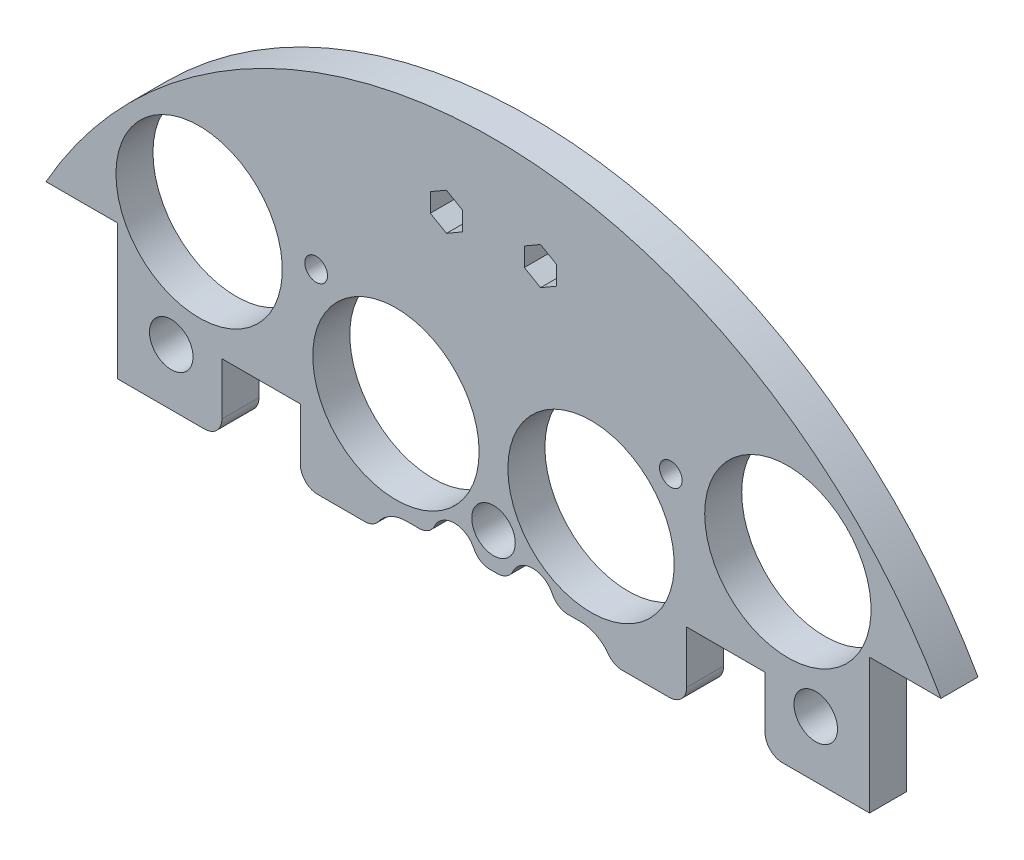
from build123d import *

# Parameters (mm, degrees)
SKETCH1_R                 = 1.651
BOSS_EXTRUDE2_DEPTH       = 5.3975
SKETCH2_R                 = 1.143
CUT_EXTRUDE1_DEPTH        = 6.3975
SKETCH3_R                 = 12.1285
CUT_EXTRUDE2_DEPTH        = 6.3975
SKETCH4_W                 = 28.562713242
SKETCH4_H                 = 11.677503754
BOSS_EXTRUDE3_DEPTH       = 5.3975
SKETCH5_W                 = 230.699333954
SKETCH5_H                 = 107.587024537
CUT_EXTRUDE3_DEPTH        = 6.3975
CUT_EXTRUDE4_DEPTH        = 6.3975
SKETCH156_W               = 11.43
SKETCH156_H               = 10.16
CUT_EXTRUDE152_DEPTH      = 6.3975
SKETCH164_R               = 1.651
CUT_EXTRUDE160_DEPTH      = 21.59
SKETCH218_R               = 3.175
CUT_EXTRUDE214_DEPTH      = 103.378
CUT_EXTRUDE214_DEPTH_BACK = 48.768
CUT_EXTRUDE155_DEPTH      = 34.544
FILLET1_R                 = 2.54


with BuildPart() as part:
    # Sketch1 → Boss-Extrude2 (new body)
    with BuildSketch(Plane.XY):
        with BuildLine():
            Line((-65.2537815, 36.83), (-54.8397815, 36.83))
            Line((-54.8397815, 36.83), (-54.8397815, -36.83))
            Line((-54.8397815, -36.83), (-65.2537815, -36.83))
            ThreePointArc((-65.2537815, -36.83), (0, -74.93), (65.2537815, -36.83))
            Line((65.2537815, -36.83), (54.8397815, -36.83))
            Line((54.8397815, -36.83), (54.8397815, 36.83))
            Line((54.8397815, 36.83), (65.2537815, 36.83))
            ThreePointArc((65.2537815, 36.83), (0, 74.93), (-65.2537815, 36.83))
        make_face()
        with Locations((-45.466, 11.049)):
            Circle(SKETCH1_R, mode=Mode.SUBTRACT)
        with Locations((-20.067270032, 10.795)):
            Circle(SKETCH1_R, mode=Mode.SUBTRACT)
        with Locations((-20.067270032, -10.795)):
            Circle(SKETCH1_R, mode=Mode.SUBTRACT)
        with Locations((-45.466, -11.049)):
            Circle(SKETCH1_R, mode=Mode.SUBTRACT)
        with Locations((45.466, -11.049)):
            Circle(SKETCH1_R, mode=Mode.SUBTRACT)
        with Locations((20.067270032, -10.795)):
            Circle(SKETCH1_R, mode=Mode.SUBTRACT)
        with Locations((20.067270032, 10.795)):
            Circle(SKETCH1_R, mode=Mode.SUBTRACT)
        with Locations((45.466, 11.049)):
            Circle(SKETCH1_R, mode=Mode.SUBTRACT)
    extrude(amount=BOSS_EXTRUDE2_DEPTH)

    # Sketch2 → Cut-Extrude1 (cut, through all)
    with BuildSketch(Plane.XY.offset(5.3975)):
        with Locations((-6.731, 62.23)):
            Circle(SKETCH2_R)
        with Locations((6.731, 62.23)):
            Circle(SKETCH2_R)
    extrude(amount=-CUT_EXTRUDE1_DEPTH, mode=Mode.SUBTRACT)

    # Sketch3 → Cut-Extrude2 (cut, through all)
    with BuildSketch(Plane(origin=(0, 0, 0), x_dir=(-1, 0, 0), z_dir=(0, 0, -1))):
        with Locations((-42.926, -42.926)):
            Circle(SKETCH3_R)
        with Locations((14.224, -34.29)):
            Circle(SKETCH3_R)
        with Locations((14.224, 34.29)):
            Circle(SKETCH3_R)
        with Locations((-42.926, 42.926)):
            Circle(SKETCH3_R)
        with Locations((42.926, 42.926)):
            Circle(SKETCH3_R)
        with Locations((-14.224, 34.29)):
            Circle(SKETCH3_R)
        with Locations((-14.224, -34.29)):
            Circle(SKETCH3_R)
        with Locations((42.926, -42.926)):
            Circle(SKETCH3_R)
    extrude(amount=-CUT_EXTRUDE2_DEPTH, mode=Mode.SUBTRACT)

    # Sketch4 → Boss-Extrude3 (add)
    with BuildSketch(Plane(origin=(0, 0, 0), x_dir=(-1, 0, 0), z_dir=(0, 0, -1))):
        with Locations((-1.488809975, 62.152540216)):
            Rectangle(SKETCH4_W, SKETCH4_H)
    extrude(amount=-BOSS_EXTRUDE3_DEPTH)

    # Sketch5 → Cut-Extrude3 (cut, through all)
    with BuildSketch(Plane(origin=(0, 0, 0), x_dir=(-1, 0, 0), z_dir=(0, 0, -1))):
        with Locations((1.971047261, -36.648512269)):
            Rectangle(SKETCH5_W, SKETCH5_H)
    extrude(amount=-CUT_EXTRUDE3_DEPTH, mode=Mode.SUBTRACT)

    # Sketch6 → Cut-Extrude4 (cut, through all)
    with BuildSketch(Plane(origin=(0, 0, 0), x_dir=(-1, 0, 0), z_dir=(0, 0, -1))):
        Polygon((4.498, 63.592546635), (6.858, 64.955093271), (9.218, 63.592546635), (9.218, 60.867453365), (6.858, 59.504906729), (4.498, 60.867453365), align=None)
        Polygon((-6.858, 64.955093271), (-9.218, 63.592546635), (-9.218, 60.867453365), (-6.858, 59.504906729), (-4.498, 60.867453365), (-4.498, 63.592546635), align=None)
    extrude(amount=-CUT_EXTRUDE4_DEPTH, mode=Mode.SUBTRACT)

    # Sketch156 → Cut-Extrude152 (cut, through all)
    with BuildSketch(Plane(origin=(0, 0, 0), x_dir=(-1, 0, 0), z_dir=(0, 0, -1))):
        with Locations((33.8847815, 22.225)):
            Rectangle(SKETCH156_W, SKETCH156_H)
        with Locations((-33.8847815, 22.225)):
            Rectangle(SKETCH156_W, SKETCH156_H)
    extrude(amount=-CUT_EXTRUDE152_DEPTH, mode=Mode.SUBTRACT)

    # Sketch164 → Cut-Extrude160 (cut)
    with BuildSketch(Plane(origin=(0, 0, 0), x_dir=(-1, 0, 0), z_dir=(0, 0, -1))):
        with Locations((25.8572, 45.466)):
            Circle(SKETCH164_R)
        with Locations((-25.8572, 45.466)):
            Circle(SKETCH164_R)
    extrude(amount=-CUT_EXTRUDE160_DEPTH, mode=Mode.SUBTRACT)

    # Sketch218 → Cut-Extrude214 (cut, two sides)
    with BuildSketch(Plane(origin=(30.092005081, 4.08352975, 11.4935), x_dir=(-1, 0, 0), z_dir=(0, 0, -1))) as cut_extrude214_sk:
        with Locations((-16.897994919, 21.31647025)):
            Circle(SKETCH218_R)
        with Locations((77.082005081, 21.31647025)):
            Circle(SKETCH218_R)
        with Locations((30.092005081, 21.31647025)):
            Circle(SKETCH218_R)
    extrude(amount=CUT_EXTRUDE214_DEPTH, mode=Mode.SUBTRACT)
    extrude(cut_extrude214_sk.sketch, amount=-CUT_EXTRUDE214_DEPTH_BACK, mode=Mode.SUBTRACT)

    # Sketch159 → Cut-Extrude155 (cut)
    with BuildSketch(Plane(origin=(0, 0, 0), x_dir=(-1, 0, 0), z_dir=(0, 0, -1))):
        with BuildLine():
            Line((-12.7, 20.24), (-8.888991966, 20.24))
            ThreePointArc((-8.888991966, 20.24), (-5.715, 23.495), (-2.541008034, 20.24))
            Line((-2.541008034, 20.24), (2.541008034, 20.24))
            ThreePointArc((2.541008034, 20.24), (5.715, 23.495), (8.888991966, 20.24))
            Line((8.888991966, 20.24), (12.7, 20.24))
            ThreePointArc((12.7, 20.24), (17.7, 15.24), (12.7, 10.24))
            Line((12.7, 10.24), (-12.7, 10.24))
            ThreePointArc((-12.7, 10.24), (-17.7, 15.24), (-12.7, 20.24))
        make_face()
    extrude(amount=-CUT_EXTRUDE155_DEPTH, mode=Mode.SUBTRACT)

    # Fillet1
    fillet1_edges = [part.edges().sort_by_distance(p)[0] for p in [
        (-39.5997815, 17.145, 2.69875),
        (-28.1697815, 17.145, 2.69875),
        (28.1697815, 17.145, 2.69875),
        (39.5997815, 17.145, 2.69875),
        (17.322875188, 17.145, 2.69875),
        (-17.322875188, 17.145, 2.69875),
        (8.888991966, 20.24, 2.69875),
        (2.541008034, 20.24, 2.69875),
        (-2.541008034, 20.24, 2.69875),
        (-8.888991966, 20.24, 2.69875),
    ]]
    fillet(fillet1_edges, radius=FILLET1_R)


solid = part.part
